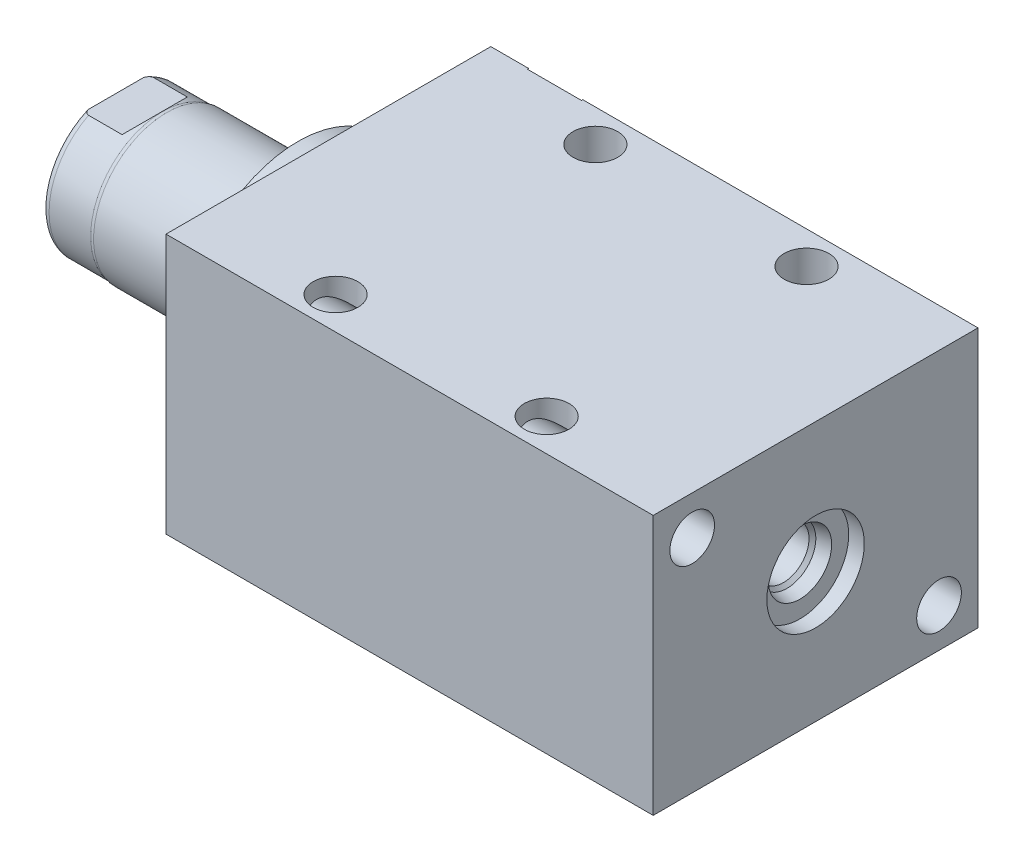
from build123d import *

# Parameters (mm, degrees)
SKETCH1_W          = 63.5
SKETCH1_H          = 50.8
EXTRUDE1_DEPTH     = 95.25
SKETCH5_R          = 22.225
EXTRUDE2_DEPTH     = 5.969
SKETCH6_W          = 14.2875
SKETCH6_H          = 35.56
CUT_EXTRUDE4_DEPTH = 30.48
HOLE1_D            = 8.7376
HOLE1_DEPTH        = 95.25
HOLE2_D            = 8.7376
HOLE2_DEPTH        = 50.8
LPATTERN1_COUNT    = 2
LPATTERN1_PITCH    = 41.275


with BuildPart() as part:
    # Sketch1 → Extrude1 (new body)
    with BuildSketch(Plane(origin=(0, 0, 0), x_dir=(0, 0, -1), z_dir=(1, 0, 0))):
        Rectangle(SKETCH1_W, SKETCH1_H)
    extrude(amount=EXTRUDE1_DEPTH)

    # S2D0002 → Cut-Revolve1 (revolve, cut)
    with BuildSketch(Plane(origin=(0, 17.4752, 0), x_dir=(-1, 0, 0), z_dir=(0, 1, 0)), mode=Mode.PRIVATE) as cut_revolve1_sk:
        Polygon((-18.8849, -31.496), (-22.225, -31.496), (-22.225, -31.75), (-12.7, -31.75), (-12.7, -17.526), (-17.6784, -17.526), (-17.6784, -28.279393135), (-18.342306865, -28.9433), align=None)
    revolve(cut_revolve1_sk.sketch.rotate(Axis((12.7, 17.4752, -19.13842003), (0, 0, 1)), 180), axis=Axis((12.7, 17.4752, -19.13842003), (0, 0, 1)), mode=Mode.SUBTRACT)  # turned: the seam where the file's is

    # Sketch3 → Cut-Revolve2 (revolve, cut)
    with BuildSketch(Plane(origin=(41.148, 0, -25.146), x_dir=(1, 0, 0), z_dir=(0, 1, 0))):
        Polygon((45.1993, 6.35), (48.5394, 6.35), (48.5394, 6.604), (39.0144, 6.604), (39.0144, -7.62), (43.9928, -7.62), (43.9928, 3.133393135), (44.656706865, 3.7973), align=None)
    revolve(axis=Axis((80.1624, 0, -3.189624441), (0, 0, -1)), mode=Mode.SUBTRACT)

    # Sketch4 → Cut-Revolve3 (revolve, cut)
    with BuildSketch(Plane(origin=(53.975, 0, 0), x_dir=(0, -1, 0), z_dir=(0, 0, 1)), mode=Mode.PRIVATE) as cut_revolve3_sk:
        Polygon((6.1849, 38.227), (9.525, 38.227), (9.525, 41.275), (0, 41.275), (0, 26.8732), (4.9784, 26.8732), (4.9784, 35.010393135), (5.642306865, 35.6743), align=None)
    revolve(cut_revolve3_sk.sketch.rotate(Axis((38.879609832, 0, 0), (1, 0, 0)), 270), axis=Axis((38.879609832, 0, 0), (1, 0, 0)), mode=Mode.SUBTRACT)  # turned: the seam where the file's is

    # Sketch5 → Extrude2 (add)
    with BuildSketch(Plane.ZY):
        Circle(SKETCH5_R)
    extrude(amount=EXTRUDE2_DEPTH)

    # Sketch6 → Revolve1 (revolve)
    with BuildSketch(Plane(origin=(0, 0, 0), x_dir=(0, 0, 1), z_dir=(0, -1, 0)), mode=Mode.PRIVATE) as revolve1_sk:
        with Locations((-7.14375, 23.749)):
            Rectangle(SKETCH6_W, SKETCH6_H)
    revolve(revolve1_sk.sketch.rotate(Axis((5.754582971, 0, 0), (-1, 0, 0)), 180), axis=Axis((5.754582971, 0, 0), (-1, 0, 0)))  # turned: the seam where the file's is

    # S2D0001 → Cut-Revolve4 (revolve, cut)
    with BuildSketch(Plane(origin=(-18.511260017, 3.2639, 0), x_dir=(0, 1, 0), z_dir=(0, 0, 1)), mode=Mode.PRIVATE) as cut_revolve4_sk:
        Polygon((2.286, 20.950017728), (2.286, 6.634739983), (-3.2639, 6.634739983), (-3.2639, 23.017739983), (3.4798, 23.017739983), align=None)
    revolve(cut_revolve4_sk.sketch.rotate(Axis((0, 0, 0), (-1, 0, 0)), 270), axis=Axis((0, 0, 0), (-1, 0, 0)), mode=Mode.SUBTRACT)  # turned: the seam where the file's is

    # Sketch8 → Cut-Revolve5 (revolve, cut)
    with BuildSketch(Plane(origin=(0, 0, 0), x_dir=(0, 0, -1), z_dir=(0, 1, 0)), mode=Mode.PRIVATE) as cut_revolve5_sk:
        with BuildLine():
            Line((-14.2875, 31.623), (-14.097, 32.385))
            Line((-14.097, 32.385), (-14.097, 40.513))
            ThreePointArc((-14.097, 40.513), (-13.996678675, 41.056796865), (-13.708922533, 41.529))
            Line((-13.708922533, 41.529), (-14.2875, 41.529))
            Line((-14.2875, 41.529), (-14.2875, 31.623))
        make_face()
    revolve(cut_revolve5_sk.sketch.rotate(Axis((-12.65936, 0, 0), (-1, 0, 0)), 180), axis=Axis((-12.65936, 0, 0), (-1, 0, 0)), mode=Mode.SUBTRACT)  # turned: the seam where the file's is

    # Sketch12 → Cut-Extrude4 (cut, symmetric)
    with BuildSketch(Plane(origin=(0, 0, 0), x_dir=(0, -1, 0), z_dir=(0, 0, -1))):
        Polygon((12.573, 41.529), (12.573, 33.9598), (14.097, 32.4358), (14.097, 41.529), align=None)
        Polygon((-12.573, 41.529), (-12.573, 33.9598), (-14.097, 32.4358), (-14.097, 41.529), align=None)
    extrude(amount=CUT_EXTRUDE4_DEPTH, both=True, mode=Mode.SUBTRACT)

    # Hole1
    with Locations(Plane.ZY):
        with Locations((-24.13, -17.78), (24.13, 17.78)):
            Hole(HOLE1_D / 2, depth=HOLE1_DEPTH)

    # Hole2
    with Locations(Plane(origin=(0, 25.4, 0), x_dir=(-1, 0, 0), z_dir=(0, 1, 0))):
        with Locations((-26.797, -25.4), (-26.797, 25.4)):
            hole2 = Hole(HOLE2_D / 2, depth=HOLE2_DEPTH)

    # LPattern1: Hole2 ×2
    with Locations(*[(i * LPATTERN1_PITCH, 0, 0) for i in range(1, LPATTERN1_COUNT)]):
        add(hole2, mode=Mode.SUBTRACT)


solid = part.part
